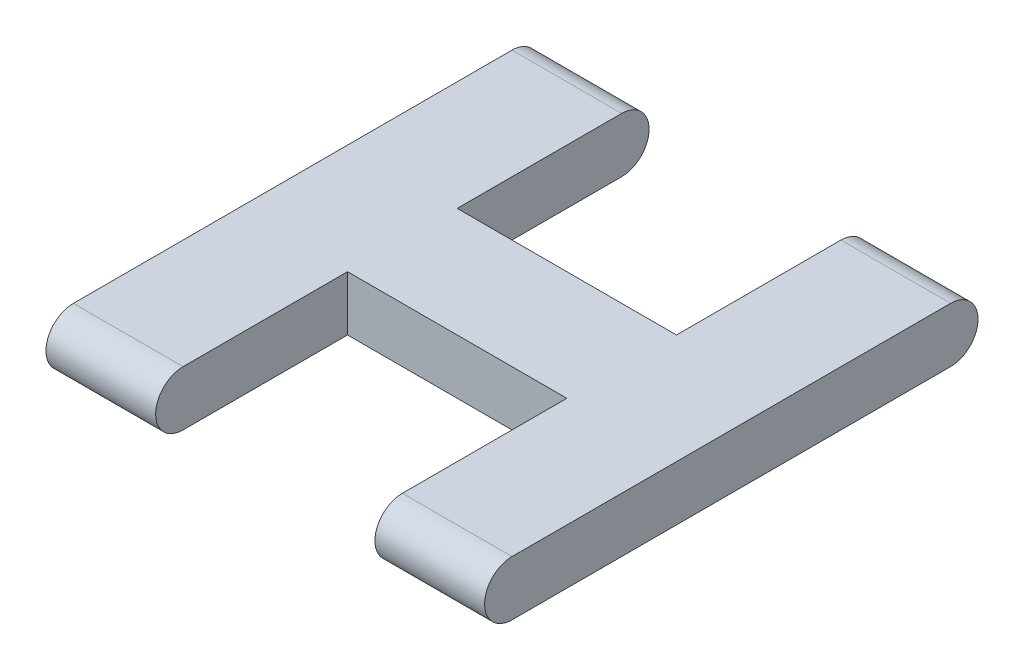
from build123d import *

# Parameters (mm, degrees)
EXTRUDE_1_DEPTH     = 16
SKETCH_2_W          = 8
SKETCH_2_H          = 9.708819165
SKETCH_2_H_2        = 9.650339741
CUT_EXTRUDE_1_DEPTH = 14


with BuildPart() as part:
    # 草图1 → 凸台-拉伸1 (new body)
    with BuildSketch(Plane(origin=(0, 0, 0), x_dir=(0, 0, -1), z_dir=(1, 0, 0))):
        with BuildLine():
            Line((-8, 1), (8, 1))
            ThreePointArc((8, 1), (9, 0), (8, -1))
            Line((8, -1), (-8, -1))
            ThreePointArc((-8, -1), (-9, 0), (-8, 1))
        make_face()
    extrude(amount=EXTRUDE_1_DEPTH)

    # 草图2 → 切除-拉伸1 (cut)
    with BuildSketch(Plane(origin=(0, 1, 0), x_dir=(1, 0, 0), z_dir=(0, 1, 0))):
        with Locations((8, 6.854409583)):
            Rectangle(SKETCH_2_W, SKETCH_2_H)
        with Locations((8, -6.825169871)):
            Rectangle(SKETCH_2_W, SKETCH_2_H_2)
    extrude(amount=-CUT_EXTRUDE_1_DEPTH, mode=Mode.SUBTRACT)


solid = part.part
